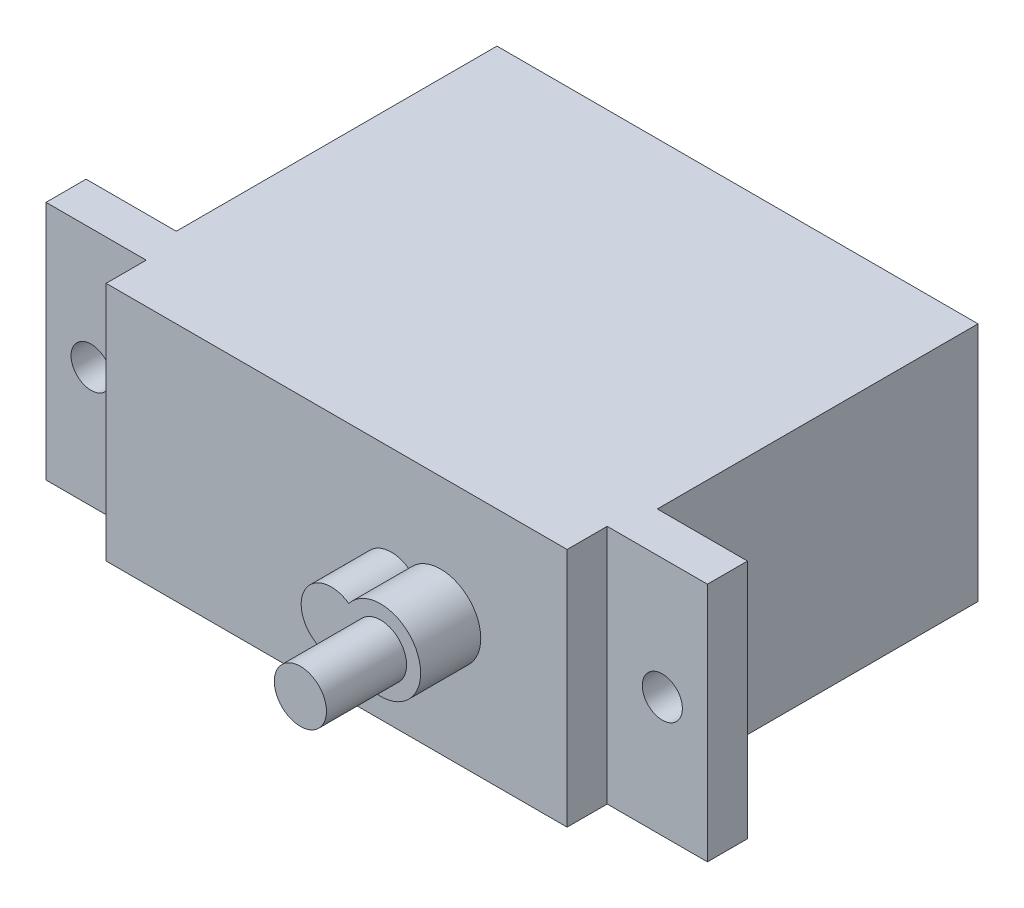
from build123d import *

# Parameters (mm, degrees)
SKETCH_1_W          = 24
SKETCH_1_H          = 16
EXTRUDE_1_DEPTH     = 12
SKETCH_2_W          = 33
SKETCH_2_H          = 12
EXTRUDE_2_DEPTH     = 2
SKETCH_3_R          = 1
CUT_EXTRUDE_1_DEPTH = 2
SKETCH_4_W          = 23
SKETCH_4_H          = 12
EXTRUDE_3_DEPTH     = 2
EXTRUDE_4_DEPTH     = 3
SKETCH_7_R          = 1.3
EXTRUDE_5_DEPTH     = 4


with BuildPart() as part:
    # 草图1 → 凸台-拉伸1 (new body)
    with BuildSketch(Plane(origin=(0, 0, 0), x_dir=(1, 0, 0), z_dir=(0, 1, 0))):
        Rectangle(SKETCH_1_W, SKETCH_1_H)
    extrude(amount=EXTRUDE_1_DEPTH)

    # 草图2 → 凸台-拉伸2 (add)
    with BuildSketch(Plane.XY.offset(8)):
        with Locations((0, 6)):
            Rectangle(SKETCH_2_W, SKETCH_2_H)
    extrude(amount=EXTRUDE_2_DEPTH)

    # 草图3 → 切除-拉伸1 (cut)
    with BuildSketch(Plane(origin=(0, 0, 8), x_dir=(-1, 0, 0), z_dir=(0, 0, -1))):
        with Locations((14.25, 6)):
            Circle(SKETCH_3_R)
        with Locations((-14.25, 6)):
            Circle(SKETCH_3_R)
    extrude(amount=-CUT_EXTRUDE_1_DEPTH, mode=Mode.SUBTRACT)

    # 草图4 → 凸台-拉伸3 (add)
    with BuildSketch(Plane.XY.offset(10)):
        with Locations((0, 6)):
            Rectangle(SKETCH_4_W, SKETCH_4_H)
    extrude(amount=EXTRUDE_3_DEPTH)

    # 草图6 → 凸台-拉伸4 (add)
    with BuildSketch(Plane.XY.offset(12)):
        with BuildLine():
            ThreePointArc((3.605751042, 4.7816434), (7.191817621, 6), (3.605751042, 7.2183566))
            ThreePointArc((3.605751042, 7.2183566), (1.230761216, 6), (3.605751042, 4.7816434))
        make_face()
    extrude(amount=EXTRUDE_4_DEPTH)

    # 草图7 → 凸台-拉伸5 (add)
    with BuildSketch(Plane.XY.offset(15)):
        with Locations((5.191817621, 6)):
            Circle(SKETCH_7_R)
    extrude(amount=EXTRUDE_5_DEPTH)


solid = part.part
